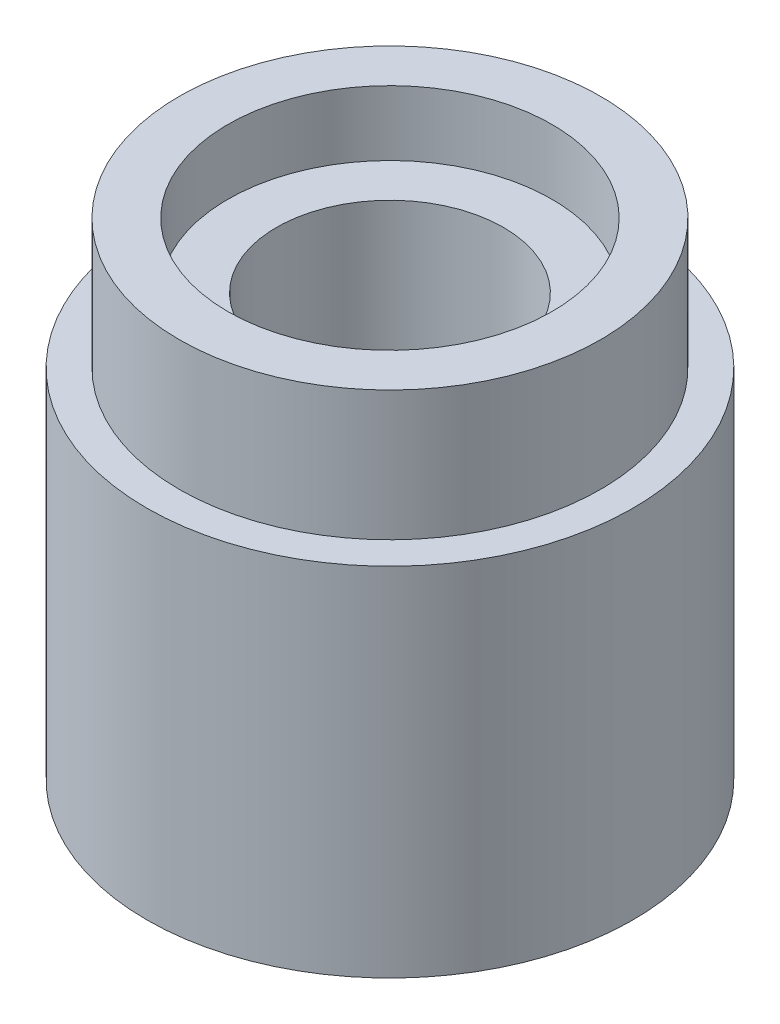
from build123d import *

# Parameters (mm, degrees)
SKETCH1_R           = 3.75
BOSS_EXTRUDE1_DEPTH = 7.5
SKETCH4_R           = 3.75
SKETCH4_R_2         = 3.25
CUT_EXTRUDE1_DEPTH  = 2
SKETCH5_R           = 1.75
CUT_EXTRUDE2_DEPTH  = 7
SKETCH6_R           = 2.5
CUT_EXTRUDE3_DEPTH  = 1


with BuildPart() as part:
    # Sketch1 → Boss-Extrude1 (new body)
    with BuildSketch(Plane(origin=(0, 0, 0), x_dir=(1, 0, 0), z_dir=(0, 1, 0))):
        Circle(SKETCH1_R)
    extrude(amount=BOSS_EXTRUDE1_DEPTH)

    # Sketch4 → Cut-Extrude1 (cut)
    with BuildSketch(Plane(origin=(0, 7.5, 0), x_dir=(1, 0, 0), z_dir=(0, 1, 0))):
        Circle(SKETCH4_R)
        Circle(SKETCH4_R_2, mode=Mode.SUBTRACT)
    extrude(amount=-CUT_EXTRUDE1_DEPTH, mode=Mode.SUBTRACT)

    # Sketch5 → Cut-Extrude2 (cut)
    with BuildSketch(Plane(origin=(0, 7.5, 0), x_dir=(1, 0, 0), z_dir=(0, 1, 0))):
        Circle(SKETCH5_R)
    extrude(amount=-CUT_EXTRUDE2_DEPTH, mode=Mode.SUBTRACT)

    # Sketch6 → Cut-Extrude3 (cut)
    with BuildSketch(Plane(origin=(0, 7.5, 0), x_dir=(1, 0, 0), z_dir=(0, 1, 0))):
        Circle(SKETCH6_R)
    extrude(amount=-CUT_EXTRUDE3_DEPTH, mode=Mode.SUBTRACT)


solid = part.part
